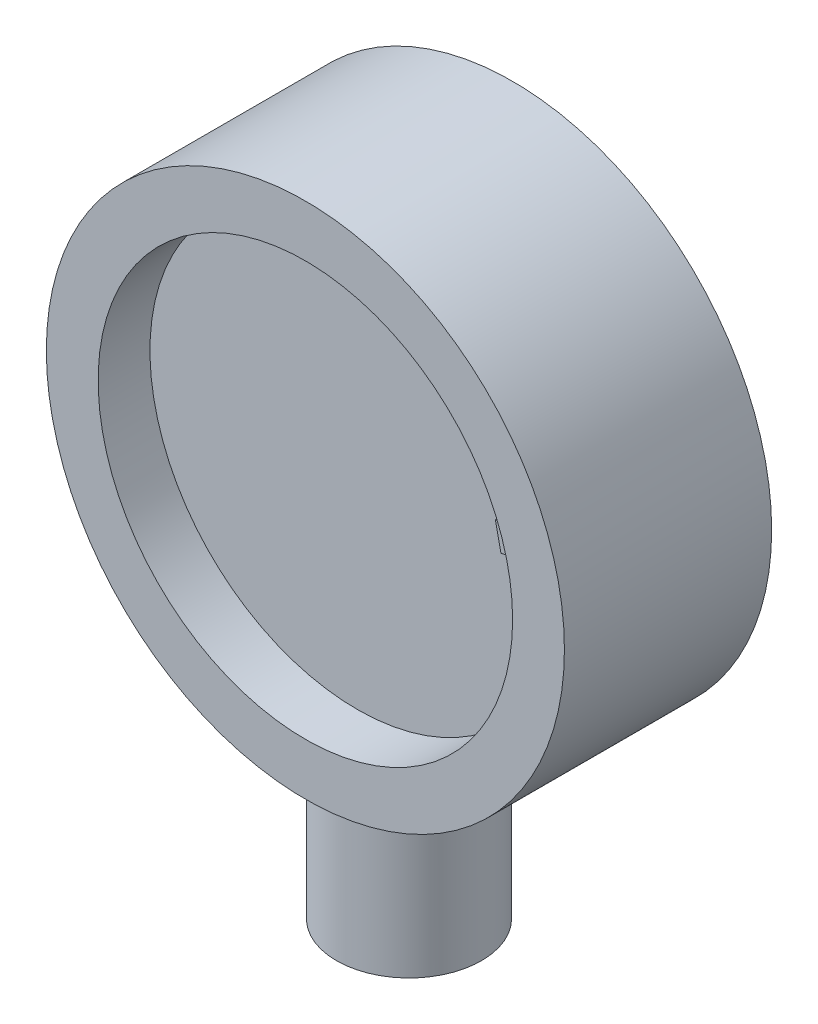
from build123d import *

# Parameters (mm, degrees)
SKETCH_1_R          = 25
EXTRUDE_1_DEPTH     = 20
SKETCH_2_R          = 7
EXTRUDE_2_DEPTH     = 40
SKETCH_3_R          = 20
CUT_EXTRUDE_1_DEPTH = 5
EXTRUDE_3_DEPTH     = 2


with BuildPart() as part:
    # Эскиз1 → Бобышка-Вытянуть1 (new body)
    with BuildSketch(Plane.XY):
        Circle(SKETCH_1_R)
    extrude(amount=EXTRUDE_1_DEPTH)

    # Эскиз2 → Бобышка-Вытянуть2 (add)
    with BuildSketch(Plane(origin=(0, 0, 0), x_dir=(1, 0, 0), z_dir=(0, 1, 0))):
        with Locations((0, -10)):
            Circle(SKETCH_2_R)
    extrude(amount=-EXTRUDE_2_DEPTH)

    # Эскиз3 → Вырез-Вытянуть1 (cut)
    with BuildSketch(Plane.XY.offset(20)):
        Circle(SKETCH_3_R)
    extrude(amount=-CUT_EXTRUDE_1_DEPTH, mode=Mode.SUBTRACT)

    # Эскиз4 → Бобышка-Вытянуть3 (add)
    with BuildSketch(Plane.XY.offset(15)):
        with BuildLine():
            Line((17.105769231, 0.186698718), (17.076121795, 0.673878205))
            Line((17.076121795, 0.673878205), (18.317307692, 0.749198718))
            add(Edge.make_bspline(
                [(18.317307692, 0.749198718), (18.314310025, 0.785130402), (18.308767326, 0.851568222), (18.286633612, 0.942102827), (18.254546657, 1.01527689), (18.216311165, 1.064084159), (18.176438073, 1.095649794), (18.135826587, 1.119796772), (18.085079758, 1.147153194), (18.023378472, 1.17672133), (17.950339328, 1.207423269), (17.867168779, 1.241265629), (17.772973596, 1.276387023), (17.706496529, 1.300039267), (17.671474359, 1.3125)],
                knots=[0, 0, 0, 0, 0.000108042, 0.000199771, 0.000278288, 0.000346114, 0.000383155, 0.000430295, 0.000487658, 0.00055611, 0.000635441, 0.000725313, 0.000825474, 0.000936993, 0.000936993, 0.000936993, 0.000936993], degree=3))
            add(Edge.make_bspline(
                [(17.671474359, 1.3125), (17.643667292, 1.322299761), (17.590032562, 1.341201703), (17.513477774, 1.369672379), (17.444661146, 1.397751496), (17.383323678, 1.424446387), (17.329014688, 1.449116095), (17.281599803, 1.471913699), (17.241949454, 1.494376078), (17.200031586, 1.522669403), (17.156051284, 1.559195094), (17.111727564, 1.60645846), (17.075391319, 1.657647066), (17.047979506, 1.716010114), (17.026979938, 1.78534735), (17.01112172, 1.870015783), (16.997415485, 1.971900649), (16.992324555, 2.045894854), (16.989583333, 2.085737179)],
                knots=[0, 0, 0, 0, 8.845e-05, 0.000170604, 0.000245002, 0.000311393, 0.000371275, 0.000423953, 0.000469174, 0.000507843, 0.000575555, 0.000640187, 0.00070176, 0.000763047, 0.00083274, 0.000918541, 0.001021211, 0.001140989, 0.001140989, 0.001140989, 0.001140989], degree=3))
            Line((16.989583333, 2.085737179), (16.983974359, 2.182692308))
            Line((16.983974359, 2.182692308), (17.387019231, 2.206730769))
            Line((17.387019231, 2.206730769), (17.391826923, 2.071314103))
            add(Edge.make_bspline(
                [(17.391826923, 2.071314103), (17.394051395, 2.042343158), (17.398100598, 1.989607397), (17.41313804, 1.920110547), (17.431944824, 1.865288161), (17.45412763, 1.840357414), (17.463942308, 1.829326923)],
                knots=[0, 0, 0, 0, 8.6986e-05, 0.000158341, 0.000213693, 0.000257618, 0.000257618, 0.000257618, 0.000257618], degree=3))
            add(Edge.make_bspline(
                [(17.463942308, 1.829326923), (17.470226295, 1.824328598), (17.484668718, 1.812841001), (17.512524566, 1.798497879), (17.546916616, 1.781580358), (17.588541943, 1.7631785), (17.637864025, 1.744064745), (17.694566685, 1.723420337), (17.75889178, 1.700832552), (17.804459466, 1.685815657), (17.828525641, 1.677884615)],
                knots=[0, 0, 0, 0, 2.4038e-05, 5.5247e-05, 9.3592e-05, 0.000139152, 0.000191678, 0.000252263, 0.000320179, 0.000396195, 0.000396195, 0.000396195, 0.000396195], degree=3))
            add(Edge.make_bspline(
                [(17.828525641, 1.677884615), (17.87296644, 1.662709876), (17.955515501, 1.634522704), (18.068011188, 1.591080263), (18.157698917, 1.54581358), (18.230430004, 1.501502379), (18.289976892, 1.448834429), (18.344106711, 1.386435778), (18.397669265, 1.312097941), (18.428990942, 1.256231711), (18.445512821, 1.226762821)],
                knots=[0, 0, 0, 0, 0.000140898, 0.000261719, 0.000361339, 0.000442031, 0.000516429, 0.000598743, 0.000689469, 0.000790751, 0.000790751, 0.000790751, 0.000790751], degree=3))
            add(Edge.make_bspline(
                [(18.445512821, 1.226762821), (18.452122409, 1.253769548), (18.46571154, 1.309294637), (18.503862109, 1.389526541), (18.551865256, 1.471602348), (18.615282822, 1.55249259), (18.690069322, 1.634957164), (18.779096113, 1.716216534), (18.880115477, 1.799016779), (18.953735363, 1.851655895), (18.991987179, 1.87900641)],
                knots=[0, 0, 0, 0, 8.321e-05, 0.000171077, 0.00026521, 0.000368099, 0.000478702, 0.000598905, 0.000729308, 0.000870342, 0.000870342, 0.000870342, 0.000870342], degree=3))
            Line((18.991987179, 1.87900641), (19.849358974, 2.466346154))
            Line((19.849358974, 2.466346154), (19.882211538, 1.931089744))
            Line((19.882211538, 1.931089744), (19.024038462, 1.357371795))
            add(Edge.make_bspline(
                [(19.024038462, 1.357371795), (19.003438036, 1.342999256), (18.963866757, 1.3153911), (18.907224821, 1.274683003), (18.856945101, 1.23455131), (18.811864717, 1.196249374), (18.772829061, 1.159352663), (18.738442264, 1.124946488), (18.710469238, 1.091306425), (18.680386785, 1.048930733), (18.652956062, 0.993265642), (18.630040822, 0.922893637), (18.618722112, 0.847051043), (18.619692314, 0.795167588), (18.620192308, 0.768429487)],
                knots=[0, 0, 0, 0, 7.5359e-05, 0.000144757, 0.000209204, 0.000268303, 0.000322156, 0.00037032, 0.000414128, 0.000453251, 0.000525996, 0.000599229, 0.000674588, 0.00075472, 0.00075472, 0.00075472, 0.00075472], degree=3))
            Line((18.620192308, 0.768429487), (19.947916667, 0.849358974))
            Line((19.947916667, 0.849358974), (19.977564103, 0.362179487))
            Line((19.977564103, 0.362179487), (17.105769231, 0.186698718))
        make_face()
        Polygon((15.87274479, 1.995935483), (15.33348197, 4.512762406), (15.792616585, 4.611320098), (16.221302483, 2.609717534), (19.653193508, 3.345294457), (19.763770431, 2.830070098), align=None)
        with BuildLine():
            Line((17.549267041, 7.14189417), (17.453113195, 7.613849298))
            add(Edge.make_bspline(
                [(17.453113195, 7.613849298), (17.493367469, 7.620143443), (17.572508796, 7.632517956), (17.690195619, 7.639031192), (17.804132184, 7.638328246), (17.914021401, 7.625834581), (18.020182596, 7.605079308), (18.122937084, 7.575564817), (18.221259492, 7.535320021), (18.31514991, 7.486107151), (18.40425571, 7.429798081), (18.485915779, 7.36421859), (18.561803839, 7.292681727), (18.631237821, 7.213894987), (18.692680087, 7.127095334), (18.747366027, 7.033415632), (18.795866234, 6.933002332), (18.82201505, 6.86221806), (18.835324733, 6.826189041)],
                knots=[0, 0, 0, 0, 0.000122158, 0.000240167, 0.000353159, 0.000463591, 0.000571392, 0.000677386, 0.000783776, 0.000889502, 0.000995083, 0.00109945, 0.001203175, 0.001307649, 0.00141393, 0.001521672, 0.001632773, 0.001747946, 0.001747946, 0.001747946, 0.001747946], degree=3))
            add(Edge.make_bspline(
                [(18.835324733, 6.826189041), (18.849901715, 6.780502136), (18.878390101, 6.691214364), (18.904233417, 6.555409917), (18.918456419, 6.422992178), (18.918814978, 6.293186302), (18.904122503, 6.166354997), (18.875775289, 6.042642184), (18.834982728, 5.921437083), (18.779313818, 5.804373911), (18.710448037, 5.692240559), (18.628162287, 5.58615694), (18.531202678, 5.488578138), (18.421550562, 5.397491585), (18.298211474, 5.314081129), (18.161485518, 5.238354082), (18.011718334, 5.168638414), (17.905372477, 5.130371511), (17.850549092, 5.11064417)],
                knots=[0, 0, 0, 0, 0.000143751, 0.000280939, 0.000413851, 0.000542857, 0.000669482, 0.000796027, 0.000922976, 0.00105237, 0.001184025, 0.001317059, 0.001454179, 0.001595861, 0.001744098, 0.001900143, 0.002064341, 0.002239059, 0.002239059, 0.002239059, 0.002239059], degree=3))
            add(Edge.make_bspline(
                [(17.850549092, 5.11064417), (17.814295505, 5.098935592), (17.742953742, 5.075894822), (17.636036154, 5.045607386), (17.530748775, 5.022868894), (17.427336918, 5.004882291), (17.325983152, 4.992563711), (17.226158174, 4.987488363), (17.128243159, 4.985964229), (17.03247239, 4.9920074), (16.93911133, 5.002485532), (16.849577962, 5.021465608), (16.763005142, 5.045048494), (16.680381025, 5.076736694), (16.600886383, 5.114180963), (16.525216018, 5.158721602), (16.452892546, 5.209070572), (16.362419658, 5.285356882), (16.259010226, 5.391391319), (16.152587053, 5.533654655), (16.063595566, 5.689307306), (16.021090151, 5.801489637), (15.999587554, 5.858240323)],
                knots=[0, 0, 0, 0, 0.000114292, 0.000224909, 0.000333201, 0.000437269, 0.000539739, 0.000639256, 0.000737016, 0.000833333, 0.000926956, 0.001018573, 0.001107616, 0.001195866, 0.001283679, 0.001370945, 0.001458973, 0.001547717, 0.001725641, 0.001901923, 0.00207953, 0.002261362, 0.002261362, 0.002261362, 0.002261362], degree=3))
            add(Edge.make_bspline(
                [(15.999587554, 5.858240323), (15.987822838, 5.894407699), (15.964770534, 5.965275651), (15.94017405, 6.071975281), (15.92372056, 6.176117451), (15.916374622, 6.277732493), (15.918181345, 6.376618541), (15.9272712, 6.473051131), (15.946970544, 6.566525694), (15.974006199, 6.657626741), (16.010021693, 6.7448827), (16.054646244, 6.827680282), (16.105931122, 6.90706519), (16.166579657, 6.981484868), (16.234639509, 7.052344109), (16.311460322, 7.117692259), (16.394812907, 7.180446325), (16.455674779, 7.21644989), (16.486767041, 7.234842887)],
                knots=[0, 0, 0, 0, 0.000114053, 0.00022348, 0.00032808, 0.000430098, 0.000528669, 0.000624505, 0.000720207, 0.000814762, 0.000909252, 0.001002813, 0.001096601, 0.001192333, 0.001290368, 0.001390925, 0.001494613, 0.001602908, 0.001602908, 0.001602908, 0.001602908], degree=3))
            Line((16.486767041, 7.234842887), (16.708722169, 6.810964682))
            add(Edge.make_bspline(
                [(16.708722169, 6.810964682), (16.669435199, 6.784812881), (16.594395723, 6.734862033), (16.499053766, 6.64544991), (16.424756084, 6.549284325), (16.371552232, 6.446684908), (16.341210187, 6.339206045), (16.329300657, 6.229110129), (16.339250209, 6.116029136), (16.360498946, 6.042523895), (16.371382425, 6.004874939)],
                knots=[0, 0, 0, 0, 0.000141398, 0.000270076, 0.000390113, 0.00050443, 0.000614495, 0.000723248, 0.000835041, 0.000952422, 0.000952422, 0.000952422, 0.000952422], degree=3))
            add(Edge.make_bspline(
                [(16.371382425, 6.004874939), (16.381782937, 5.976865201), (16.402211091, 5.921849905), (16.441702542, 5.844730604), (16.487679984, 5.774379091), (16.54008057, 5.710708136), (16.59867085, 5.653391225), (16.664322889, 5.6035541), (16.735871015, 5.559972567), (16.814046164, 5.523951051), (16.898663792, 5.495079397), (16.99069525, 5.478535507), (17.088868793, 5.468884785), (17.193766142, 5.47273557), (17.305296713, 5.483433201), (17.423231877, 5.505924959), (17.547939739, 5.537162673), (17.632216777, 5.564455875), (17.675869605, 5.578592887)],
                knots=[0, 0, 0, 0, 8.9575e-05, 0.000175939, 0.00025928, 0.000341254, 0.000422851, 0.000504586, 0.000588, 0.000673681, 0.000762367, 0.000855398, 0.000953551, 0.001057746, 0.001169688, 0.001289446, 0.001417516, 0.001555134, 0.001555134, 0.001555134, 0.001555134], degree=3))
            add(Edge.make_bspline(
                [(17.675869605, 5.578592887), (17.719559676, 5.594482797), (17.803958352, 5.625178269), (17.923919303, 5.676259182), (18.032128539, 5.731352079), (18.128741774, 5.789743068), (18.213888018, 5.851521672), (18.286733397, 5.917467054), (18.349773904, 5.985524319), (18.399508406, 6.058364119), (18.438658544, 6.133228392), (18.469572414, 6.209089338), (18.491641379, 6.286413429), (18.503340145, 6.365302934), (18.506939534, 6.445416705), (18.499916661, 6.526778122), (18.485054558, 6.609587869), (18.468126621, 6.663947058), (18.459523451, 6.691573657)],
                knots=[0, 0, 0, 0, 0.000139455, 0.000269394, 0.000390877, 0.000503426, 0.000607758, 0.000705911, 0.000797811, 0.000885382, 0.000969612, 0.001050854, 0.001130762, 0.001210202, 0.001289594, 0.001370777, 0.001454701, 0.001541432, 0.001541432, 0.001541432, 0.001541432], degree=3))
            add(Edge.make_bspline(
                [(18.459523451, 6.691573657), (18.451347643, 6.713629493), (18.435320617, 6.756865517), (18.405407407, 6.817938963), (18.371758528, 6.874324458), (18.333760621, 6.926198933), (18.291320763, 6.973402128), (18.244660385, 7.016136821), (18.193541771, 7.054051077), (18.138531622, 7.087807935), (18.078836712, 7.115839618), (18.015325499, 7.138482019), (17.947604165, 7.154483371), (17.875657866, 7.163756337), (17.799829796, 7.167949152), (17.719783664, 7.16493167), (17.635648005, 7.157360033), (17.578585703, 7.147143456), (17.549267041, 7.14189417)],
                knots=[0, 0, 0, 0, 7.0531e-05, 0.000138262, 0.000203673, 0.000267298, 0.000330848, 0.000393803, 0.000456784, 0.00052151, 0.000587102, 0.000654262, 0.000723451, 0.00079541, 0.000871638, 0.000951001, 0.001035516, 0.00112483, 0.00112483, 0.00112483, 0.00112483], degree=3))
        make_face()
        Polygon((18.403110047, 8.003344912), (14.193975432, 7.303825681), (14.028110047, 7.657191066), (18.236443381, 8.359114143), align=None)
        with BuildLine():
            Line((15.618888402, 10.723721775), (15.424176864, 11.163625621))
            add(Edge.make_bspline(
                [(15.424176864, 11.163625621), (15.462144504, 11.178445819), (15.536600531, 11.207508807), (15.649961575, 11.238984525), (15.761227329, 11.262291752), (15.870996062, 11.274038709), (15.979026532, 11.276597896), (16.085063015, 11.269661597), (16.189470002, 11.251773571), (16.291514232, 11.22357754), (16.39050604, 11.186990157), (16.485087936, 11.141923299), (16.574012824, 11.08802644), (16.658391595, 11.025982911), (16.736360309, 10.95419457), (16.810718241, 10.875300978), (16.880114835, 10.787922838), (16.920477537, 10.724118083), (16.941003787, 10.691670493)],
                knots=[0, 0, 0, 0, 0.0001222, 0.000239639, 0.000352469, 0.000462901, 0.0005703, 0.000676314, 0.000781172, 0.000887501, 0.000993477, 0.001097412, 0.001201301, 0.001304989, 0.001411064, 0.00151877, 0.001630022, 0.001745142, 0.001745142, 0.001745142, 0.001745142], degree=3))
            add(Edge.make_bspline(
                [(16.941003787, 10.691670493), (16.96506158, 10.650166684), (17.012104877, 10.569008949), (17.067432887, 10.442429604), (17.108692729, 10.315993632), (17.136156245, 10.189548045), (17.15025738, 10.063034374), (17.149049104, 9.936190856), (17.134859499, 9.809307645), (17.105683625, 9.683020238), (17.0624824, 9.558756167), (17.004486548, 9.438027998), (16.931344542, 9.321659433), (16.843807447, 9.209473118), (16.74112335, 9.101849161), (16.624247701, 8.998205041), (16.492592124, 8.89867421), (16.397125419, 8.838159806), (16.348055069, 8.807055109)],
                knots=[0, 0, 0, 0, 0.000143825, 0.00028124, 0.000413512, 0.000542229, 0.000668766, 0.00079457, 0.000921991, 0.001051057, 0.001182578, 0.001315899, 0.001451966, 0.001594137, 0.00174207, 0.001897581, 0.002062326, 0.002236565, 0.002236565, 0.002236565, 0.002236565], degree=3))
            add(Edge.make_bspline(
                [(16.348055069, 8.807055109), (16.282997327, 8.769762815), (16.156474306, 8.697237495), (15.961158714, 8.611860757), (15.767992805, 8.550974022), (15.608177117, 8.51923584), (15.482610208, 8.506994503), (15.391248039, 8.505368517), (15.301716013, 8.510857417), (15.214468273, 8.523989827), (15.128923683, 8.542648677), (15.046212845, 8.570708984), (14.964820097, 8.604169719), (14.859813892, 8.658625389), (14.736503471, 8.74068), (14.601502035, 8.855882101), (14.481385018, 8.988784378), (14.415698434, 9.088968829), (14.382510197, 9.13958716)],
                knots=[0, 0, 0, 0, 0.000224846, 0.000437277, 0.000637991, 0.000831439, 0.000924805, 0.001016165, 0.001105284, 0.00119356, 0.001280645, 0.001367558, 0.001455206, 0.00154444, 0.001722008, 0.001898177, 0.002075782, 0.002257157, 0.002257157, 0.002257157, 0.002257157], degree=3))
            add(Edge.make_bspline(
                [(14.382510197, 9.13958716), (14.363259604, 9.172412572), (14.325624307, 9.236586916), (14.279608987, 9.335946693), (14.240442876, 9.433498161), (14.211306501, 9.530837136), (14.192344906, 9.627771044), (14.180509339, 9.723650587), (14.179162082, 9.819219407), (14.186381666, 9.913610221), (14.201913233, 10.006683408), (14.228464089, 10.09701886), (14.261837278, 10.185490644), (14.304482261, 10.271381938), (14.356174074, 10.35443969), (14.417026834, 10.434407665), (14.4845851, 10.513843219), (14.53637883, 10.562091327), (14.562798659, 10.586702544)],
                knots=[0, 0, 0, 0, 0.000114098, 0.000223063, 0.000328114, 0.000429269, 0.000527327, 0.000624133, 0.000718698, 0.000813524, 0.000907844, 0.001001179, 0.001095526, 0.001191205, 0.001288371, 0.001388532, 0.001492479, 0.001600712, 0.001600712, 0.001600712, 0.001600712], degree=3))
            Line((14.562798659, 10.586702544), (14.869689684, 10.220516647))
            add(Edge.make_bspline(
                [(14.869689684, 10.220516647), (14.8370993, 10.186696009), (14.774852452, 10.122099408), (14.701851743, 10.01445952), (14.648760914, 9.905500066), (14.619525676, 9.793779582), (14.612564588, 9.682366118), (14.624438757, 9.572361778), (14.657633089, 9.464026892), (14.694551684, 9.397288846), (14.713439684, 9.363144852)],
                knots=[0, 0, 0, 0, 0.000140679, 0.000268694, 0.000388407, 0.000502685, 0.000612697, 0.000721536, 0.000833055, 0.000949877, 0.000949877, 0.000949877, 0.000949877], degree=3))
            add(Edge.make_bspline(
                [(14.713439684, 9.363144852), (14.729434062, 9.337897873), (14.76087376, 9.288270595), (14.816843617, 9.222117706), (14.876231275, 9.162507386), (14.941485904, 9.112267012), (15.01084704, 9.069137201), (15.085499025, 9.034647378), (15.164576733, 9.007194785), (15.24874241, 8.989005917), (15.337378483, 8.978522796), (15.430730475, 8.982020893), (15.528249691, 8.994656494), (15.629647158, 9.019665192), (15.736022119, 9.053980799), (15.846128154, 9.101252525), (15.96139539, 9.158108509), (16.037700279, 9.202917297), (16.077221736, 9.226125621)],
                knots=[0, 0, 0, 0, 8.9561e-05, 0.000176047, 0.000259338, 0.000341563, 0.000422508, 0.000503881, 0.000587755, 0.000673102, 0.000761766, 0.000854746, 0.000952545, 0.001056329, 0.001167569, 0.001287515, 0.001415444, 0.001552896, 0.001552896, 0.001552896, 0.001552896], degree=3))
            add(Edge.make_bspline(
                [(16.077221736, 9.226125621), (16.116475962, 9.250836433), (16.192495053, 9.298690987), (16.298342196, 9.374423986), (16.391739875, 9.451858098), (16.473994184, 9.528988242), (16.543184496, 9.607848601), (16.600968619, 9.687016994), (16.647358955, 9.766978974), (16.68018266, 9.848764297), (16.702470641, 9.930082965), (16.716671238, 10.010575611), (16.720465017, 10.090741233), (16.715741986, 10.170011723), (16.702037364, 10.248864387), (16.678346975, 10.326977692), (16.645767258, 10.404740653), (16.617297161, 10.454236334), (16.602862761, 10.47933075)],
                knots=[0, 0, 0, 0, 0.000139137, 0.000269451, 0.000390102, 0.000502889, 0.000607364, 0.000704332, 0.000796563, 0.000883906, 0.000967888, 0.001049166, 0.001128594, 0.001208067, 0.001286976, 0.001368099, 0.001452481, 0.001539261, 0.001539261, 0.001539261, 0.001539261], degree=3))
            add(Edge.make_bspline(
                [(16.602862761, 10.47933075), (16.590461148, 10.499127803), (16.566044122, 10.538105404), (16.522781142, 10.590541029), (16.478528615, 10.639252632), (16.429644468, 10.68107182), (16.378184421, 10.718050047), (16.323863419, 10.750570621), (16.265428653, 10.775931461), (16.204676238, 10.796835516), (16.140956567, 10.812523676), (16.074242082, 10.820357382), (16.004725757, 10.820854845), (15.932636115, 10.815113371), (15.857792506, 10.803129078), (15.780444334, 10.783475968), (15.700252301, 10.756879992), (15.646544539, 10.734992476), (15.618888402, 10.723721775)],
                knots=[0, 0, 0, 0, 7.0006e-05, 0.000137831, 0.000203595, 0.000267215, 0.000330369, 0.000393584, 0.000456718, 0.00052108, 0.000586186, 0.000653174, 0.000722089, 0.000794422, 0.000869904, 0.000949195, 0.001033573, 0.001123148, 0.001123148, 0.001123148, 0.001123148], degree=3))
        make_face()
        Polygon((13.784582186, 10.123217572), (13.290191161, 10.697736803), (14.542595007, 12.772256034), (12.249325776, 11.9076727), (11.792595007, 12.4389227), (13.972883468, 14.314723982), (14.290992443, 13.945332957), (12.535383468, 12.43491629), (14.845479622, 13.300300906), (15.12993475, 12.9701727), (13.814229622, 10.777865008), (15.653973212, 12.360397059), (15.964870648, 11.999018854), align=None)
        with BuildLine():
            Line((11.275149874, 15.963697581), (11.571624233, 16.323473222))
            Line((11.571624233, 16.323473222), (13.585246028, 14.664018093))
            add(Edge.make_bspline(
                [(13.585246028, 14.664018093), (13.566998416, 14.64170819), (13.530675905, 14.597299545), (13.468279687, 14.538052697), (13.401051567, 14.484705657), (13.35239195, 14.454686005), (13.32803449, 14.439659119)],
                knots=[0, 0, 0, 0, 8.639e-05, 0.000171962, 0.000257561, 0.000343354, 0.000343354, 0.000343354, 0.000343354], degree=3))
            add(Edge.make_bspline(
                [(13.32803449, 14.439659119), (13.285475009, 14.416557165), (13.198935382, 14.369582097), (13.057818459, 14.315300097), (12.906881567, 14.269373596), (12.772918573, 14.240305473), (12.658600686, 14.222642751), (12.565613033, 14.21071081), (12.466526737, 14.200142085), (12.360947889, 14.192472639), (12.249307149, 14.185821556), (12.130938955, 14.18217013), (12.006464512, 14.179662019), (11.921251755, 14.179384331), (11.877713977, 14.179242452)],
                knots=[0, 0, 0, 0, 0.00014514, 0.000295126, 0.000452539, 0.000618193, 0.000705797, 0.000799519, 0.000899423, 0.001004696, 0.001117059, 0.001234915, 0.001359938, 0.00149055, 0.00149055, 0.00149055, 0.00149055], degree=3))
            add(Edge.make_bspline(
                [(11.877713977, 14.179242452), (11.810671882, 14.179214851), (11.681648694, 14.179161731), (11.495173212, 14.175238469), (11.323426196, 14.167832528), (11.165702429, 14.158963662), (11.022535096, 14.145072106), (10.893716267, 14.129282584), (10.779062201, 14.11151429), (10.677754225, 14.088784662), (10.58666135, 14.062694324), (10.502727438, 14.034028208), (10.425190655, 14.001148044), (10.353369217, 13.965319855), (10.288010024, 13.924976408), (10.228856636, 13.880940085), (10.175037963, 13.833820941), (10.144431277, 13.798465248), (10.129316541, 13.781005273)],
                knots=[0, 0, 0, 0, 0.000201123, 0.000387064, 0.000559491, 0.000716836, 0.000860911, 0.000990909, 0.001106174, 0.001208816, 0.001302151, 0.001390335, 0.001474718, 0.001554629, 0.001630903, 0.001704782, 0.001775717, 0.001844924, 0.001844924, 0.001844924, 0.001844924], degree=3))
            add(Edge.make_bspline(
                [(10.129316541, 13.781005273), (10.114788502, 13.762577558), (10.086070875, 13.726151427), (10.049912861, 13.667396561), (10.021077915, 13.606595193), (9.999241291, 13.54363258), (9.983099575, 13.47935065), (9.974112301, 13.412694992), (9.972960028, 13.344236201), (9.977381808, 13.274424327), (9.989581996, 13.204954266), (10.008041914, 13.136974108), (10.033464309, 13.071232969), (10.067149196, 13.008377376), (10.106243698, 12.947099491), (10.153161303, 12.888507538), (10.206898675, 12.832296802), (10.246810231, 12.797782175), (10.267137054, 12.780203991)],
                knots=[0, 0, 0, 0, 7.0353e-05, 0.000139068, 0.000206452, 0.000271833, 0.000338686, 0.00040498, 0.000473108, 0.000543785, 0.000614525, 0.00068431, 0.000754841, 0.000825449, 0.000897907, 0.000972615, 0.001050257, 0.00113084, 0.00113084, 0.00113084, 0.00113084], degree=3))
            add(Edge.make_bspline(
                [(10.267137054, 12.780203991), (10.289493638, 12.76235944), (10.333066742, 12.727580312), (10.402703924, 12.68468799), (10.472056787, 12.647955354), (10.54240284, 12.61866684), (10.614391841, 12.598939152), (10.686506636, 12.585744126), (10.759618588, 12.580949181), (10.832966629, 12.584164976), (10.906070893, 12.595369172), (10.977814694, 12.614747744), (11.047892762, 12.642239756), (11.116141482, 12.677606763), (11.182531368, 12.721320348), (11.2461536, 12.773930126), (11.309304081, 12.832970101), (11.347670374, 12.877576916), (11.36729731, 12.900396299)],
                knots=[0, 0, 0, 0, 8.5741e-05, 0.00016711, 0.000244883, 0.000321068, 0.000395143, 0.000468389, 0.000540664, 0.000614452, 0.000688226, 0.000762088, 0.000836934, 0.000913627, 0.0009923, 0.001074894, 0.001161046, 0.001251278, 0.001251278, 0.001251278, 0.001251278], degree=3))
            Line((11.36729731, 12.900396299), (11.719861413, 12.543825786))
            add(Edge.make_bspline(
                [(11.719861413, 12.543825786), (11.687281791, 12.511972479), (11.623842612, 12.449947583), (11.521820675, 12.369067832), (11.419767382, 12.298763554), (11.315232434, 12.241328241), (11.209380392, 12.195366531), (11.101776279, 12.16123601), (10.992263869, 12.140555653), (10.881930248, 12.130732943), (10.77066879, 12.133133659), (10.659606055, 12.148013844), (10.548587824, 12.173441433), (10.438326366, 12.21187884), (10.328361521, 12.260811063), (10.21884454, 12.321544181), (10.109406264, 12.393745573), (10.039420653, 12.449510855), (10.003515259, 12.478120657)],
                knots=[0, 0, 0, 0, 0.000136606, 0.000266, 0.000390013, 0.000508, 0.000623209, 0.000735732, 0.000845893, 0.000956887, 0.00106749, 0.001179003, 0.001292514, 0.00140857, 0.001528736, 0.001653182, 0.001783858, 0.001921531, 0.001921531, 0.001921531, 0.001921531], degree=3))
            add(Edge.make_bspline(
                [(10.003515259, 12.478120657), (9.968611869, 12.508350001), (9.900430572, 12.567400878), (9.808181985, 12.661946626), (9.727723607, 12.759436056), (9.66055979, 12.860802613), (9.603957362, 12.964318771), (9.55909802, 13.070712202), (9.528172521, 13.180634935), (9.507847356, 13.292274454), (9.500458237, 13.404005545), (9.502028756, 13.513856647), (9.516990661, 13.620678915), (9.541833347, 13.724567079), (9.577121958, 13.825480868), (9.624345928, 13.922967462), (9.681792803, 14.018135982), (9.728287436, 14.077143601), (9.751912695, 14.107127068)],
                knots=[0, 0, 0, 0, 0.000138476, 0.000270503, 0.000395775, 0.000517115, 0.000634718, 0.000749302, 0.000862668, 0.000976622, 0.001089087, 0.001198088, 0.00130563, 0.001411939, 0.001518123, 0.001625641, 0.001736404, 0.001850827, 0.001850827, 0.001850827, 0.001850827], degree=3))
            add(Edge.make_bspline(
                [(9.751912695, 14.107127068), (9.77768602, 14.136891462), (9.829376695, 14.196586576), (9.919299157, 14.27458363), (10.016914124, 14.344883754), (10.123821095, 14.407165821), (10.242483593, 14.461687741), (10.374926523, 14.506191607), (10.520858151, 14.545283494), (10.653131589, 14.569161213), (10.769948579, 14.584630613), (10.869830382, 14.595986539), (10.980758937, 14.605120492), (11.102501411, 14.614495049), (11.235337544, 14.620095239), (11.379011751, 14.62613942), (11.533687741, 14.629776704), (11.640533988, 14.631748014), (11.695822951, 14.632768093)],
                knots=[0, 0, 0, 0, 0.000117987, 0.000236634, 0.000356049, 0.000478498, 0.000607216, 0.000747094, 0.000897139, 0.001060115, 0.001149866, 0.001250652, 0.001361647, 0.00148376, 0.001616927, 0.001760466, 0.001915166, 0.002081062, 0.002081062, 0.002081062, 0.002081062], degree=3))
            add(Edge.make_bspline(
                [(11.695822951, 14.632768093), (11.74123043, 14.633205892), (11.828043734, 14.634042906), (11.952233956, 14.636752872), (12.064159767, 14.638856762), (12.163800417, 14.641943736), (12.251118936, 14.646218392), (12.326486413, 14.649790962), (12.389510336, 14.654713729), (12.48486103, 14.663463251), (12.611734159, 14.684395102), (12.71826971, 14.716619019), (12.7695409, 14.732127068)],
                knots=[0, 0, 0, 0, 0.000136227, 0.000260449, 0.000372655, 0.000472065, 0.000559497, 0.000634924, 0.000698407, 0.000749117, 0.00092221, 0.001082797, 0.001082797, 0.001082797, 0.001082797], degree=3))
            Line((12.7695409, 14.732127068), (11.275149874, 15.963697581))
        make_face()
    extrude(amount=EXTRUDE_3_DEPTH)


solid = part.part
